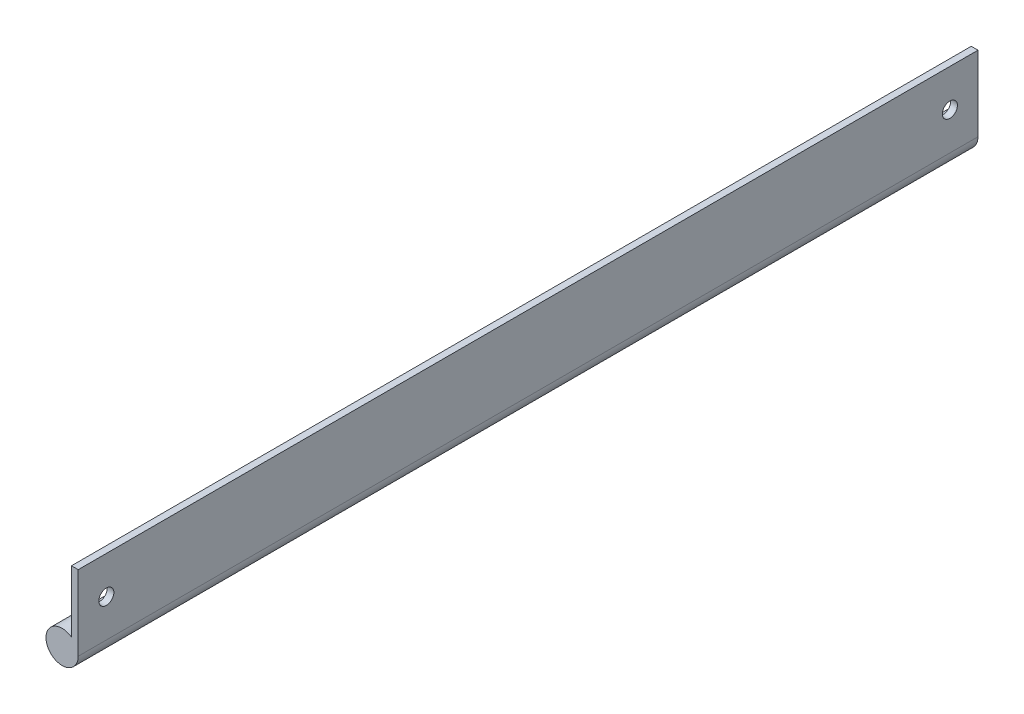
from build123d import *

# Parameters (mm, degrees)
BOSS_EXTRUDE1_DEPTH    = 304.8
F_10_CLEARANCE_HOLE1_D = 5.1054


with BuildPart() as part:
    # Sketch1 → Boss-Extrude1 (new body)
    with BuildSketch(Plane.XY):
        with BuildLine():
            Line((-1.143, -8.256814656), (-1.143, 12.7))
            Line((-1.143, 12.7), (1.143, 12.7))
            Line((1.143, 12.7), (1.143, -12.7))
            ThreePointArc((1.143, -12.7), (-9.173985791, -15.198384078), (-1.143, -8.256814656))
        make_face()
    extrude(amount=BOSS_EXTRUDE1_DEPTH)

    # #10 Clearance Hole1 (through all)
    with Locations(Plane.ZY.offset(1.143)):
        with Locations((9.525, 0), (295.275, 0)):
            Hole(F_10_CLEARANCE_HOLE1_D / 2)


solid = part.part
